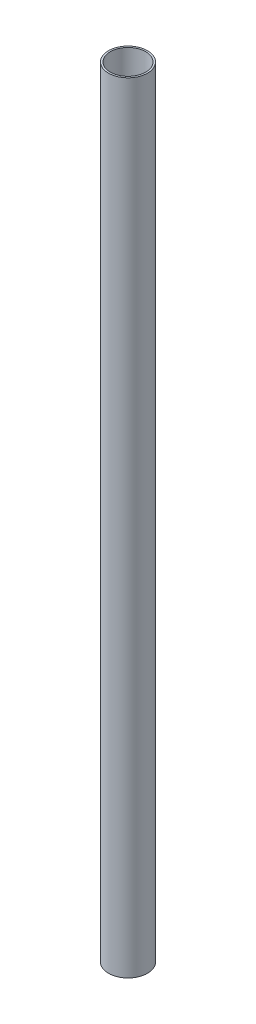
from build123d import *

# Parameters (mm, degrees)
SKETCH1_R      = 11
SKETCH1_R_2    = 10
EXTRUDE1_DEPTH = 220


with BuildPart() as part:
    # Sketch1 → Extrude1 (new body, symmetric)
    with BuildSketch(Plane(origin=(0, 0, 0), x_dir=(1, 0, 0), z_dir=(0, 1, 0))):
        Circle(SKETCH1_R)
        Circle(SKETCH1_R_2, mode=Mode.SUBTRACT)
    extrude(amount=EXTRUDE1_DEPTH, both=True)


solid = part.part
